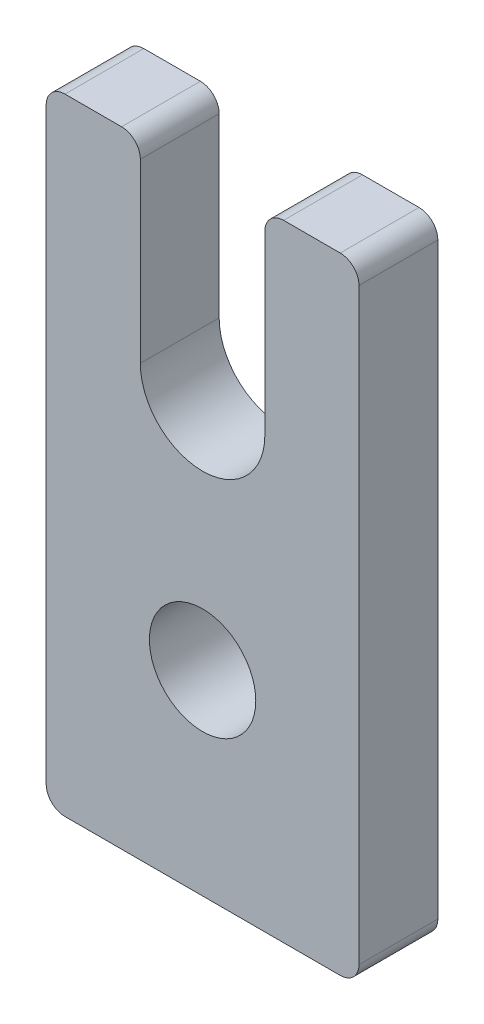
from build123d import *

# Parameters (mm, degrees)
SKETCH1_R           = 2.159
BOSS_EXTRUDE1_DEPTH = 3.2004
FILLET1_R           = 0.762


with BuildPart() as part:
    # Sketch1 → Boss-Extrude1 (new body)
    with BuildSketch(Plane.XY):
        with BuildLine():
            Line((0, 25.4), (0, 0))
            Line((0, 0), (12.7, 0))
            Line((12.7, 0), (12.7, 25.4))
            Line((12.7, 25.4), (8.8773, 25.4))
            Line((8.8773, 25.4), (8.8773, 17.4625))
            ThreePointArc((8.8773, 17.4625), (6.35, 14.9352), (3.8227, 17.4625))
            Line((3.8227, 17.4625), (3.8227, 25.4))
            Line((3.8227, 25.4), (0, 25.4))
        make_face()
        with Locations((6.35, 7.9375)):
            Circle(SKETCH1_R, mode=Mode.SUBTRACT)
    extrude(amount=BOSS_EXTRUDE1_DEPTH)

    # Fillet1
    fillet1_edges = [part.edges().sort_by_distance(p)[0] for p in [
        (3.8227, 25.4, 1.6002),
        (8.8773, 25.4, 1.6002),
        (12.7, 25.4, 1.6002),
        (12.7, 0, 1.6002),
        (0, 0, 1.6002),
        (0, 25.4, 1.6002),
    ]]
    fillet(fillet1_edges, radius=FILLET1_R)


solid = part.part
